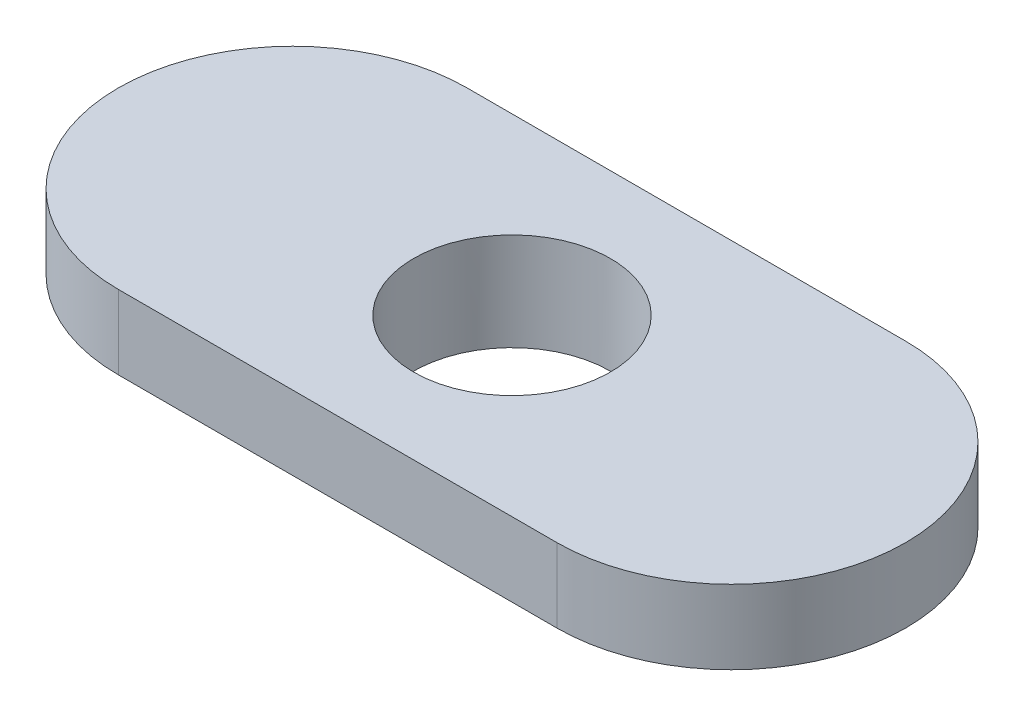
from build123d import *

# Parameters (mm, degrees)
BOSS_EXTRUDE2_START = -6.35
SKETCH8_R           = 3.175
BOSS_EXTRUDE2_DEPTH = 2.3876
SKETCH9_R           = 3.5687
SKETCH9_R_2         = 3.175
BOSS_EXTRUDE3_DEPTH = 0.762


with BuildPart() as part:
    # Sketch8 → Boss-Extrude2 (new body)
    with BuildSketch(Plane(origin=(0, 0, 0), x_dir=(1, 0, 0), z_dir=(0, 1, 0)).offset(BOSS_EXTRUDE2_START)):
        with BuildLine():
            Line((-7.0739, 5.6261), (7.0739, 5.6261))
            ThreePointArc((7.0739, 5.6261), (12.7, 0), (7.0739, -5.6261))
            Line((7.0739, -5.6261), (-7.0739, -5.6261))
            ThreePointArc((-7.0739, -5.6261), (-12.7, 0), (-7.0739, 5.6261))
        make_face()
        Circle(SKETCH8_R, mode=Mode.SUBTRACT)
    extrude(amount=-BOSS_EXTRUDE2_DEPTH)

    # Sketch9 → Boss-Extrude3 (add)
    with BuildSketch(Plane.XZ.offset(8.7376)):
        Circle(SKETCH9_R)
        Circle(SKETCH9_R_2, mode=Mode.SUBTRACT)
    extrude(amount=BOSS_EXTRUDE3_DEPTH)


solid = part.part
